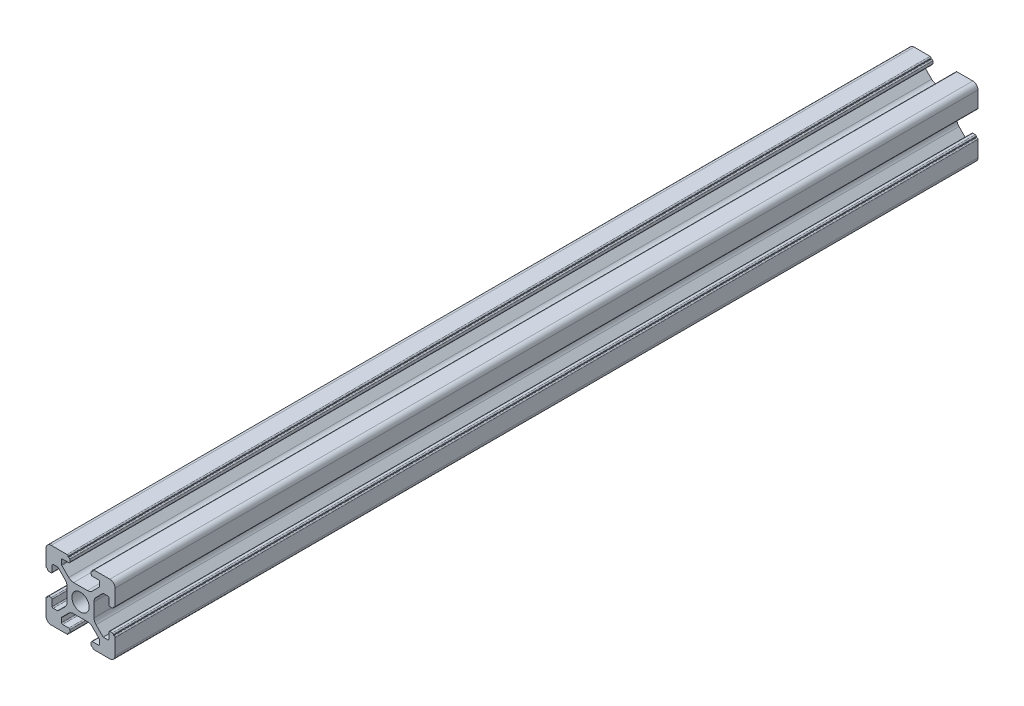
from build123d import *

# Parameters (mm, degrees)
MODEL_R             = 5
BOSS_EXTRUDE1_DEPTH = 500


with BuildPart() as part:
    # Model → Boss-Extrude1 (new body)
    with BuildSketch(Plane.XY):
        with BuildLine():
            Line((7.8, 0), (7.8, -4.021825407))
            ThreePointArc((7.8, -4.021825407), (8.10448187, -5.552559136), (8.971572875, -6.850252532))
            Line((8.971572875, -6.850252532), (13.121320343, -11))
            Line((13.121320343, -11), (15.8, -11))
            ThreePointArc((15.8, -11), (16.224264069, -10.824264069), (16.4, -10.4))
            Line((16.4, -10.4), (16.4, -6.8))
            ThreePointArc((16.4, -6.8), (16.575735931, -6.375735931), (17, -6.2))
            Line((17, -6.2), (18.4, -6.2))
            ThreePointArc((18.4, -6.2), (18.824264069, -6.375735931), (19, -6.8))
            Line((19, -6.8), (19, -7.2))
            Line((19, -7.2), (19.4, -7.2))
            ThreePointArc((19.4, -7.2), (19.824264068, -7.375735931), (20, -7.8))
            Line((20, -7.8), (20, -17))
            ThreePointArc((20, -17), (19.121320343, -19.121320343), (17, -20))
            Line((17, -20), (7.8, -20))
            ThreePointArc((7.8, -20), (7.375735931, -19.824264069), (7.2, -19.4))
            ThreePointArc((7.2, -19.4), (7.082842712, -19.117157287), (6.8, -19))
            ThreePointArc((6.8, -19), (6.375735931, -18.824264069), (6.2, -18.4))
            Line((6.2, -18.4), (6.2, -16.999999999))
            ThreePointArc((6.2, -16.999999999), (6.375735931, -16.575735931), (6.8, -16.4))
            Line((6.8, -16.4), (10.4, -16.4))
            ThreePointArc((10.4, -16.4), (10.824264069, -16.224264069), (11, -15.8))
            Line((11, -15.8), (11, -13.369848481))
            ThreePointArc((11, -13.369848481), (10.954327719, -13.140238421), (10.824264069, -12.945584412))
            Line((10.824264069, -12.945584412), (6.850252532, -8.971572875))
            ThreePointArc((6.850252532, -8.971572875), (5.552559136, -8.10448187), (4.021825407, -7.8))
            Line((4.021825407, -7.8), (0, -7.8))
            Line((0, -7.8), (-4.021825407, -7.8))
            ThreePointArc((-4.021825407, -7.8), (-5.552559136, -8.10448187), (-6.850252532, -8.971572875))
            Line((-6.850252532, -8.971572875), (-10.824264069, -12.945584412))
            ThreePointArc((-10.824264069, -12.945584412), (-10.954327719, -13.140238421), (-11, -13.369848481))
            Line((-11, -13.369848481), (-11, -15.8))
            ThreePointArc((-11, -15.8), (-10.824264069, -16.224264069), (-10.4, -16.4))
            Line((-10.4, -16.4), (-6.8, -16.4))
            ThreePointArc((-6.8, -16.4), (-6.375735931, -16.575735931), (-6.2, -16.999999999))
            Line((-6.2, -16.999999999), (-6.2, -18.4))
            ThreePointArc((-6.2, -18.4), (-6.375735931, -18.824264069), (-6.8, -19))
            ThreePointArc((-6.8, -19), (-7.082842712, -19.117157287), (-7.2, -19.4))
            ThreePointArc((-7.2, -19.4), (-7.375735931, -19.824264069), (-7.8, -20))
            Line((-7.8, -20), (-17, -20))
            ThreePointArc((-17, -20), (-19.121320343, -19.121320343), (-20, -17))
            Line((-20, -17), (-20, -7.8))
            ThreePointArc((-20, -7.8), (-19.824264069, -7.375735931), (-19.4, -7.2))
            Line((-19.4, -7.2), (-19, -7.2))
            Line((-19, -7.2), (-19, -6.8))
            ThreePointArc((-19, -6.8), (-18.824264069, -6.375735931), (-18.4, -6.2))
            Line((-18.4, -6.2), (-17, -6.2))
            ThreePointArc((-17, -6.2), (-16.575735931, -6.375735931), (-16.4, -6.8))
            Line((-16.4, -6.8), (-16.4, -10.4))
            ThreePointArc((-16.4, -10.4), (-16.224264069, -10.824264069), (-15.8, -11))
            Line((-15.8, -11), (-13.369848481, -11))
            ThreePointArc((-13.369848481, -11), (-13.140238421, -10.954327719), (-12.945584412, -10.824264069))
            Line((-12.945584412, -10.824264069), (-8.971572875, -6.850252532))
            ThreePointArc((-8.971572875, -6.850252532), (-8.10448187, -5.552559136), (-7.8, -4.021825407))
            Line((-7.8, -4.021825407), (-7.8, 0))
            Line((-7.8, 0), (-7.8, 4.021825407))
            ThreePointArc((-7.8, 4.021825407), (-8.10448187, 5.552559136), (-8.971572875, 6.850252532))
            Line((-8.971572875, 6.850252532), (-12.945584412, 10.824264069))
            ThreePointArc((-12.945584412, 10.824264069), (-13.140238421, 10.954327719), (-13.369848481, 11))
            Line((-13.369848481, 11), (-15.8, 11))
            ThreePointArc((-15.8, 11), (-16.224264069, 10.824264069), (-16.4, 10.4))
            Line((-16.4, 10.4), (-16.4, 6.8))
            ThreePointArc((-16.4, 6.8), (-16.575735931, 6.375735931), (-17, 6.2))
            Line((-17, 6.2), (-18.4, 6.2))
            ThreePointArc((-18.4, 6.2), (-18.824264069, 6.375735931), (-19, 6.8))
            Line((-19, 6.8), (-19, 7.2))
            Line((-19, 7.2), (-19.4, 7.2))
            ThreePointArc((-19.4, 7.2), (-19.824264069, 7.375735931), (-20, 7.8))
            Line((-20, 7.8), (-20, 17))
            ThreePointArc((-20, 17), (-19.121320343, 19.121320343), (-17, 20))
            Line((-17, 20), (-7.8, 20))
            ThreePointArc((-7.8, 20), (-7.375735931, 19.824264068), (-7.2, 19.4))
            Line((-7.2, 19.4), (-7.2, 19))
            Line((-7.2, 19), (-6.8, 19))
            ThreePointArc((-6.8, 19), (-6.375735931, 18.824264069), (-6.2, 18.4))
            Line((-6.2, 18.4), (-6.2, 16.999999999))
            ThreePointArc((-6.2, 16.999999999), (-6.375735931, 16.575735931), (-6.8, 16.4))
            Line((-6.8, 16.4), (-10.4, 16.4))
            ThreePointArc((-10.4, 16.4), (-10.824264069, 16.224264069), (-11, 15.8))
            Line((-11, 15.8), (-11, 13.369848481))
            ThreePointArc((-11, 13.369848481), (-10.954327719, 13.140238421), (-10.824264069, 12.945584412))
            Line((-10.824264069, 12.945584412), (-6.850252532, 8.971572875))
            ThreePointArc((-6.850252532, 8.971572875), (-5.552559136, 8.10448187), (-4.021825407, 7.8))
            Line((-4.021825407, 7.8), (0, 7.8))
            Line((0, 7.8), (4.021825407, 7.8))
            ThreePointArc((4.021825407, 7.8), (5.552559136, 8.10448187), (6.850252532, 8.971572875))
            Line((6.850252532, 8.971572875), (10.824264069, 12.945584412))
            ThreePointArc((10.824264069, 12.945584412), (10.954327719, 13.140238421), (11, 13.369848481))
            Line((11, 13.369848481), (11, 15.8))
            ThreePointArc((11, 15.8), (10.824264069, 16.224264069), (10.4, 16.4))
            Line((10.4, 16.4), (6.8, 16.4))
            ThreePointArc((6.8, 16.4), (6.375735931, 16.575735931), (6.2, 16.999999999))
            Line((6.2, 16.999999999), (6.2, 18.4))
            ThreePointArc((6.2, 18.4), (6.375735931, 18.824264069), (6.8, 19))
            Line((6.8, 19), (7.2, 19))
            Line((7.2, 19), (7.2, 19.4))
            ThreePointArc((7.2, 19.4), (7.375735931, 19.824264068), (7.8, 20))
            Line((7.8, 20), (17, 20))
            ThreePointArc((17, 20), (19.121320343, 19.121320343), (20, 17))
            Line((20, 17), (20, 7.8))
            ThreePointArc((20, 7.8), (19.824264068, 7.375735931), (19.4, 7.2))
            Line((19.4, 7.2), (19, 7.2))
            Line((19, 7.2), (19, 6.8))
            ThreePointArc((19, 6.8), (18.824264069, 6.375735931), (18.4, 6.2))
            Line((18.4, 6.2), (17, 6.2))
            ThreePointArc((17, 6.2), (16.575735931, 6.375735931), (16.4, 6.8))
            Line((16.4, 6.8), (16.4, 10.4))
            ThreePointArc((16.4, 10.4), (16.224264069, 10.824264069), (15.8, 11))
            Line((15.8, 11), (13.369848481, 11))
            ThreePointArc((13.369848481, 11), (13.140238421, 10.954327719), (12.945584412, 10.824264069))
            Line((12.945584412, 10.824264069), (8.971572875, 6.850252532))
            ThreePointArc((8.971572875, 6.850252532), (8.10448187, 5.552559136), (7.8, 4.021825407))
            Line((7.8, 4.021825407), (7.8, 0))
        make_face()
        Circle(MODEL_R, mode=Mode.SUBTRACT)
    extrude(amount=BOSS_EXTRUDE1_DEPTH)


solid = part.part
